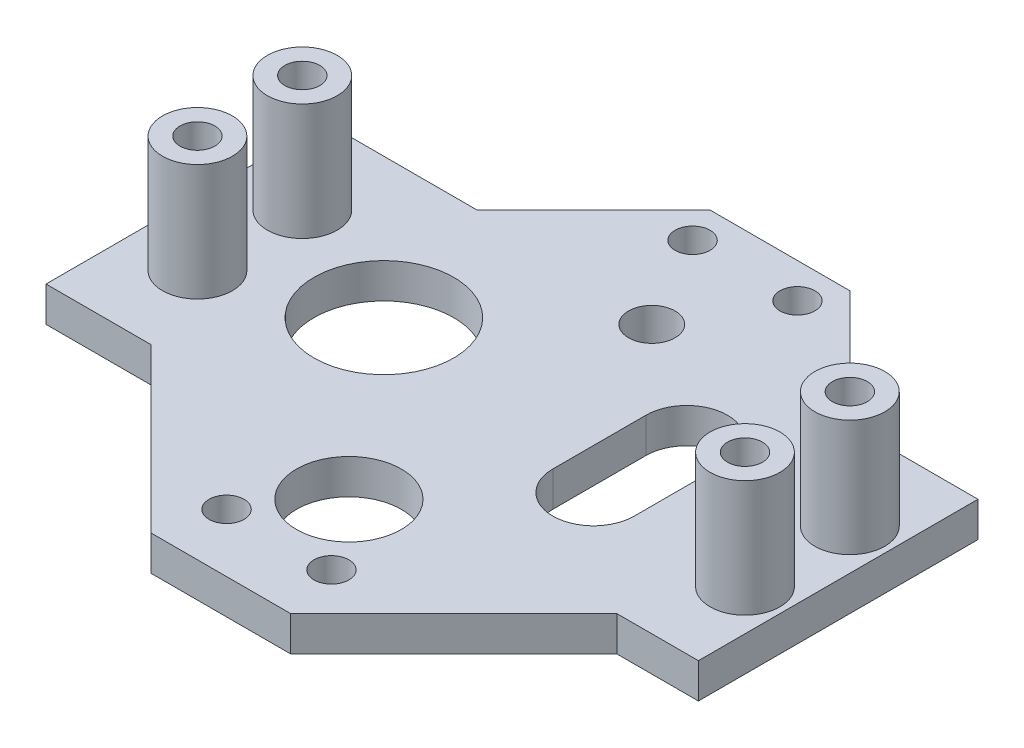
from build123d import *

# Parameters (mm, degrees)
SKETCH1_W           = 12
SKETCH1_H           = 10
SKETCH1_H_2         = 24
SKETCH1_H_3         = 14
BOSS_EXTRUDE1_DEPTH = 3
SKETCH2_R           = 1.5
SKETCH2_R_2         = 2
SKETCH2_R_3         = 4.5
CUT_EXTRUDE1_DEPTH  = 3
SKETCH3_R           = 3
BOSS_EXTRUDE2_DEPTH = 10
SKETCH4_R           = 1.5
SKETCH4_R_2         = 6
CUT_EXTRUDE2_DEPTH  = 4
SKETCH5_R           = 1.5
CUT_EXTRUDE3_DEPTH  = 10


with BuildPart() as part:
    # Sketch1 → Boss-Extrude1 (new body)
    with BuildSketch(Plane(origin=(0, 0, 0), x_dir=(1, 0, 0), z_dir=(0, 1, 0))):
        Polygon((0, 0), (0, 14), (-14, 14), align=None)
        Polygon((0, 38), (-10, 38), (-23, 38), (-23, 14), (-14, 14), (0, 14), align=None)
        Polygon((22, 38), (12, 48), (12, 38), align=None)
        with Locations((6, 43)):
            Rectangle(SKETCH1_W, SKETCH1_H)
        with Locations((6, 26)):
            Rectangle(SKETCH1_W, SKETCH1_H_2)
        Polygon((22, 38), (12, 38), (12, 14), (26, 14), (33, 14), (33, 38), align=None)
        Polygon((26, 14), (12, 14), (12, 0), align=None)
        with Locations((6, 7)):
            Rectangle(SKETCH1_W, SKETCH1_H_3)
        Polygon((0, 38), (0, 48), (-10, 38), align=None)
    extrude(amount=BOSS_EXTRUDE1_DEPTH)

    # Sketch2 → Cut-Extrude1 (cut)
    with BuildSketch(Plane(origin=(0, 3, 0), x_dir=(1, 0, 0), z_dir=(0, 1, 0))):
        with Locations((1.5, 45)):
            Circle(SKETCH2_R)
        with Locations((10.5, 45)):
            Circle(SKETCH2_R)
        with Locations((10.5, 5)):
            Circle(SKETCH2_R)
        with Locations((1.5, 5)):
            Circle(SKETCH2_R)
        with Locations((6, 37)):
            Circle(SKETCH2_R_2)
        with Locations((6, 11)):
            Circle(SKETCH2_R_3)
    extrude(amount=-CUT_EXTRUDE1_DEPTH, mode=Mode.SUBTRACT)

    # Sketch3 → Boss-Extrude2 (add)
    with BuildSketch(Plane(origin=(0, 3, 0), x_dir=(1, 0, 0), z_dir=(0, 1, 0))):
        with Locations((-17.5, 30.5)):
            Circle(SKETCH3_R)
        with Locations((-17.5, 21.5)):
            Circle(SKETCH3_R)
        with Locations((29.5, 30.5)):
            Circle(SKETCH3_R)
        with Locations((29.5, 21.5)):
            Circle(SKETCH3_R)
    extrude(amount=BOSS_EXTRUDE2_DEPTH)

    # Sketch4 → Cut-Extrude2 (cut, through all)
    with BuildSketch(Plane(origin=(0, 3, 0), x_dir=(1, 0, 0), z_dir=(0, 1, 0))):
        with Locations((23, 26)):
            Circle(SKETCH4_R)
        with Locations((-6, 26)):
            Circle(SKETCH4_R_2)
        with BuildLine():
            Line((12.5, 22), (12.5, 30))
            ThreePointArc((12.5, 30), (16, 33.5), (19.5, 30))
            Line((19.5, 30), (19.5, 22))
            ThreePointArc((19.5, 22), (16, 18.5), (12.5, 22))
        make_face()
    extrude(amount=-CUT_EXTRUDE2_DEPTH, mode=Mode.SUBTRACT)

    # Sketch5 → Cut-Extrude3 (cut)
    with BuildSketch(Plane(origin=(0, 13, 0), x_dir=(1, 0, 0), z_dir=(0, 1, 0))):
        with Locations((29.5, 30.5)):
            Circle(SKETCH5_R)
        with Locations((29.5, 21.5)):
            Circle(SKETCH5_R)
        with Locations((-17.5, 30.5)):
            Circle(SKETCH5_R)
        with Locations((-17.5, 21.5)):
            Circle(SKETCH5_R)
    extrude(amount=-CUT_EXTRUDE3_DEPTH, mode=Mode.SUBTRACT)


solid = part.part
